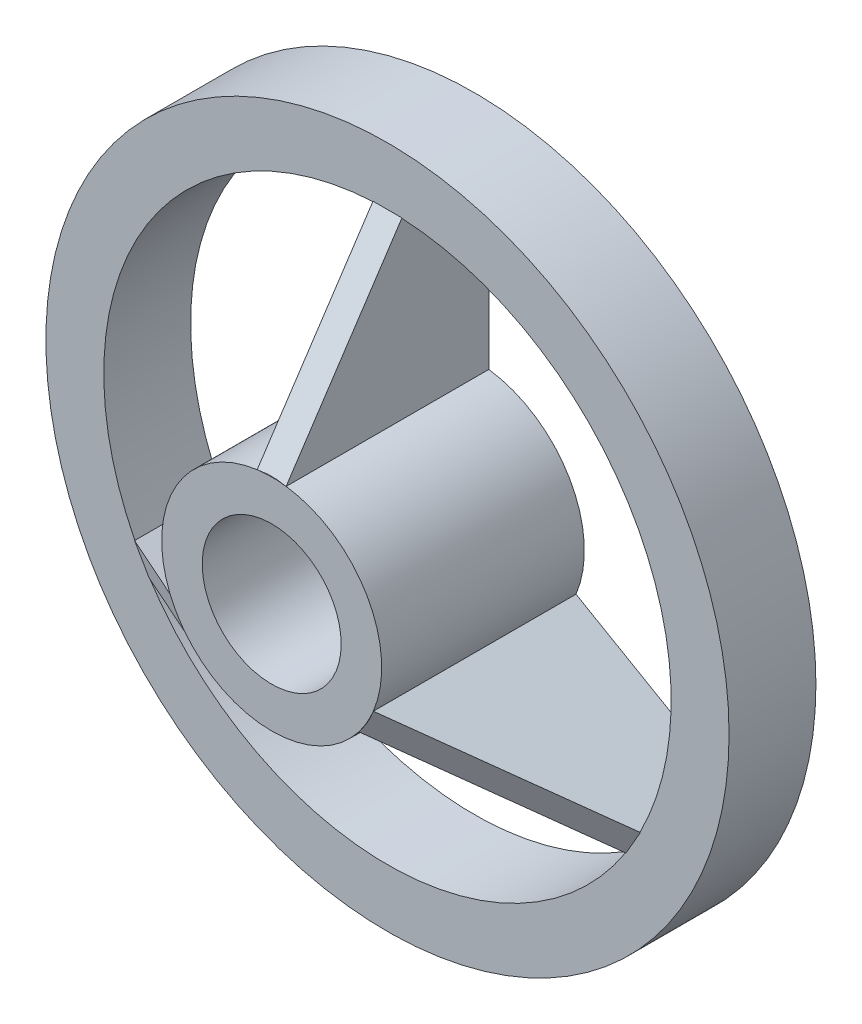
from build123d import *

# Parameters (mm, degrees)
SKETCH1_R           = 1.9
SKETCH1_R_2         = 1.2
BOSS_EXTRUDE1_DEPTH = 3.5
SKETCH2_R           = 5.9
SKETCH2_R_2         = 4.9
BOSS_EXTRUDE2_DEPTH = 1.5
BOSS_EXTRUDE3_DEPTH = 0.25
CIRPATTERN1_COUNT   = 3


with BuildPart() as part:
    # Sketch1 → Boss-Extrude1 (new body)
    with BuildSketch(Plane.XY):
        Circle(SKETCH1_R)
        Circle(SKETCH1_R_2, mode=Mode.SUBTRACT)
    extrude(amount=BOSS_EXTRUDE1_DEPTH)



with BuildPart() as body_2:
    # Sketch2 → Boss-Extrude2 (new body)
    with BuildSketch(Plane.XY):
        Circle(SKETCH2_R)
        Circle(SKETCH2_R_2, mode=Mode.SUBTRACT)
    extrude(amount=BOSS_EXTRUDE2_DEPTH)


with BuildPart() as part_1:
    add(part.part)

    add(body_2.part)  # Boss-Extrude3 merges body 2
    # Sketch3 → Boss-Extrude3 (add, symmetric)
    with BuildSketch(Plane(origin=(0, 0, 0), x_dir=(0, 0, -1), z_dir=(1, 0, 0))):
        Polygon((0, 4.9), (-1.5, 4.9), (-3.5, 1.885172848), (-3.5, 1.643172848), (0, 1.643172848), align=None)
    boss_extrude3 = extrude(amount=BOSS_EXTRUDE3_DEPTH, both=True)

    # CirPattern1: Boss-Extrude3 ×3 about axis
    cirpattern1_axis = Axis((0, 0, 3.5), (0, 0, -1))
    for i in range(1, CIRPATTERN1_COUNT):
        add(boss_extrude3.rotate(cirpattern1_axis, i * 360 / CIRPATTERN1_COUNT))


solid = part_1.part
